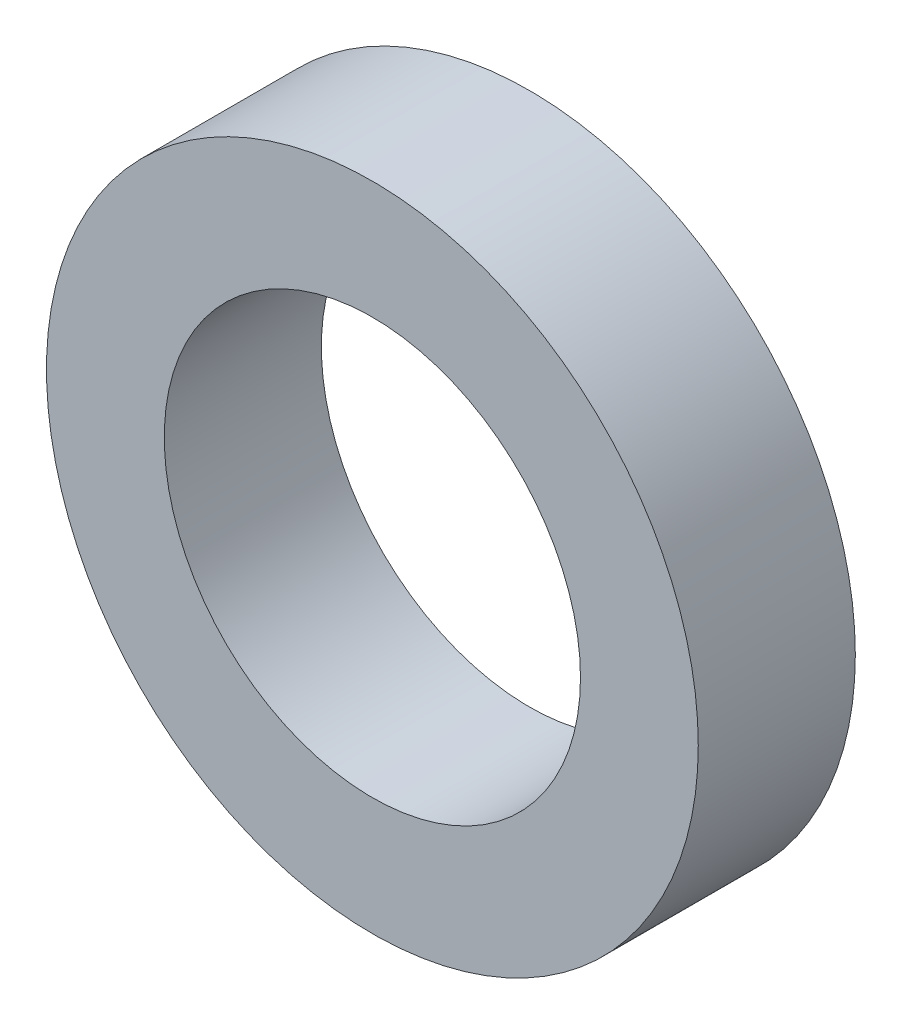
from build123d import *

# Parameters (mm, degrees)
SKETCH1_R           = 4.15
SKETCH1_R_2         = 2.65
BOSS_EXTRUDE1_DEPTH = 2


with BuildPart() as part:
    # Sketch1 → Boss-Extrude1 (new body)
    with BuildSketch(Plane.XY):
        Circle(SKETCH1_R)
        Circle(SKETCH1_R_2, mode=Mode.SUBTRACT)
    extrude(amount=BOSS_EXTRUDE1_DEPTH)


solid = part.part
